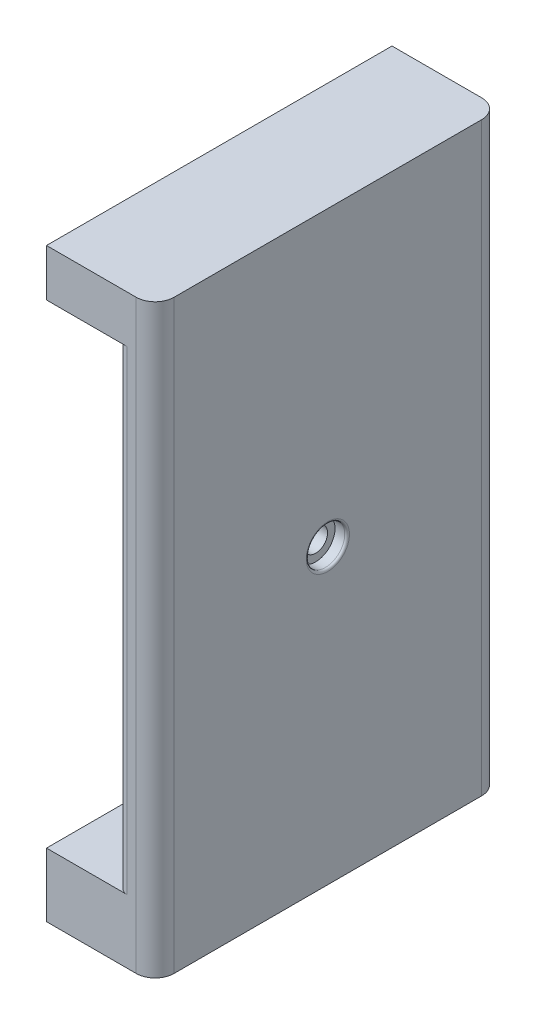
from build123d import *

# Parameters (mm, degrees)
SKETCH1_W           = 12
SKETCH1_H           = 18.25
SKETCH2_R           = 3.7145
CUT_EXTRUDE1_DEPTH  = 8.5725
SKETCH3_W           = 73.152
SKETCH3_H           = 124
BOSS_EXTRUDE1_DEPTH = 8
FILLET1_R           = 4
SKETCH6_R           = 13.15
CUT_EXTRUDE2_DEPTH  = 12
SKETCH12_R          = 4.075
CUT_EXTRUDE6_DEPTH  = 2.56
SKETCH12_6_R        = 2.5
CUT_EXTRUDE7_DEPTH  = 8
FILLET2_R           = 0.5
SKETCH13_W          = 73.152
SKETCH13_H          = 13.5
SKETCH13_H_2        = 10
BOSS_EXTRUDE3_DEPTH = 15
FILLET3_R           = 2
SKETCH14_R          = 3.71375
CUT_EXTRUDE8_DEPTH  = 9.5


with BuildPart() as part:
    # Sketch1 → Revolve1 (revolve)
    with BuildSketch(Plane.XY):
        with Locations((14.255, 9.125)):
            Rectangle(SKETCH1_W, SKETCH1_H)
    revolve(axis=Axis((8.255, 0, 0), (1, 0, 0)))

    # Sketch2 → Cut-Extrude1 (cut)
    with BuildSketch(Plane.ZY.offset(-8.255)):
        Circle(SKETCH2_R)
    extrude(amount=-CUT_EXTRUDE1_DEPTH, mode=Mode.SUBTRACT)

    # Sketch6 → Cut-Extrude2 (cut)
    with BuildSketch(Plane.ZY.offset(-8.255)):
        Circle(SKETCH6_R)
    extrude(amount=-CUT_EXTRUDE2_DEPTH, mode=Mode.SUBTRACT)


with BuildPart() as body_2:
    # Sketch3 → Boss-Extrude1 (new body)
    with BuildSketch(Plane(origin=(20.255, 0, 0), x_dir=(0, 0, -1), z_dir=(1, 0, 0))):
        Rectangle(SKETCH3_W, SKETCH3_H)
    extrude(amount=BOSS_EXTRUDE1_DEPTH)

    # Fillet1
    fillet1_edges = [body_2.edges().sort_by_distance(p)[0] for p in [
        (28.255, 0, -36.576),
        (28.255, 0, 36.576),
    ]]
    fillet(fillet1_edges, radius=FILLET1_R)

    # Sketch12 → Cut-Extrude6 (cut)
    with BuildSketch(Plane(origin=(28.255, 0, 0), x_dir=(0, 0, -1), z_dir=(1, 0, 0))):
        Circle(SKETCH12_R)
    extrude(amount=-CUT_EXTRUDE6_DEPTH, mode=Mode.SUBTRACT)

    # Sketch12_6 → Cut-Extrude7 (cut)
    with BuildSketch(Plane(origin=(28.255, 0, 0), x_dir=(0, 0, -1), z_dir=(1, 0, 0))):
        Circle(SKETCH12_6_R)
    extrude(amount=-CUT_EXTRUDE7_DEPTH, mode=Mode.SUBTRACT)

    # Fillet2
    fillet2_edges = [body_2.edges().sort_by_distance(p)[0] for p in [
        (28.255, 0, 4.075),
    ]]
    fillet(fillet2_edges, radius=FILLET2_R)


with BuildPart() as part_1:
    add(part.part)

    # Combine1: union body 2
    add(body_2.part)

    # Sketch13 → Boss-Extrude3 (add)
    with BuildSketch(Plane.ZY.offset(-20.255)):
        with Locations((0, -55.25)):
            Rectangle(SKETCH13_W, SKETCH13_H)
        with Locations((0, 57)):
            Rectangle(SKETCH13_W, SKETCH13_H_2)
    extrude(amount=BOSS_EXTRUDE3_DEPTH)

    # Fillet3
    fillet3_edges = [part_1.edges().sort_by_distance(p)[0] for p in [
        (20.255, -18.25, 0),
        (20.255, 1.75, 36.576),
        (20.255, 1.75, -36.576),
    ]]
    fillet(fillet3_edges, radius=FILLET3_R)

    # Sketch14 → Cut-Extrude8 (cut)
    with BuildSketch(Plane.XZ.offset(62)):
        with Locations((18.42, 12.75)):
            Circle(SKETCH14_R)
        with Locations((18.42, -12.75)):
            Circle(SKETCH14_R)
    extrude(amount=-CUT_EXTRUDE8_DEPTH, mode=Mode.SUBTRACT)


solid = part_1.part
